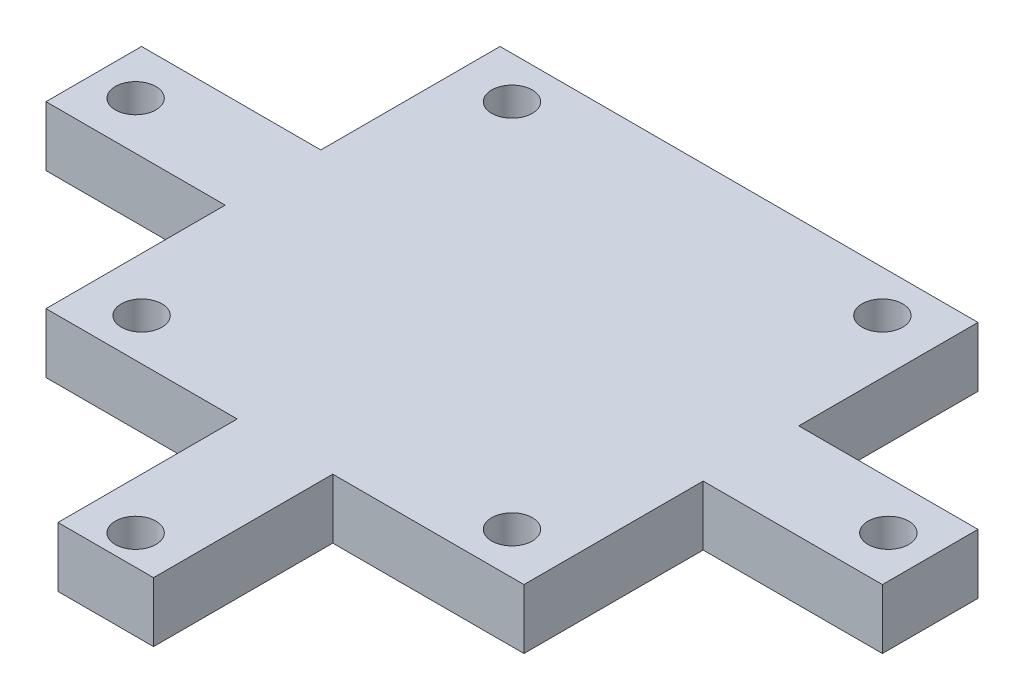
from build123d import *

# Parameters (mm, degrees)
CROQUIS1_R              = 1.7
SALIENTE_EXTRUIR1_DEPTH = 5


with BuildPart() as part:
    # Croquis1 → Saliente-Extruir1 (new body)
    with BuildSketch(Plane(origin=(0, 0, 0), x_dir=(1, 0, 0), z_dir=(0, 1, 0))):
        Polygon((-35, 4), (-20, 4), (-20, 19), (20, 19), (20, 4), (35, 4), (35, -4), (20, -4), (20, -19), (4, -19), (4, -34), (-4, -34), (-4, -19), (-20, -19), (-20, -4), (-35, -4), align=None)
        with Locations((-15.5, 15.5)):
            Circle(CROQUIS1_R, mode=Mode.SUBTRACT)
        with Locations((15.5, 15.5)):
            Circle(CROQUIS1_R, mode=Mode.SUBTRACT)
        with Locations((15.5, -15.5)):
            Circle(CROQUIS1_R, mode=Mode.SUBTRACT)
        with Locations((-15.5, -15.5)):
            Circle(CROQUIS1_R, mode=Mode.SUBTRACT)
        with Locations((-31.5, 0)):
            Circle(CROQUIS1_R, mode=Mode.SUBTRACT)
        with Locations((0, -31.5)):
            Circle(CROQUIS1_R, mode=Mode.SUBTRACT)
        with Locations((31.5, 0)):
            Circle(CROQUIS1_R, mode=Mode.SUBTRACT)
    extrude(amount=SALIENTE_EXTRUIR1_DEPTH)


solid = part.part
